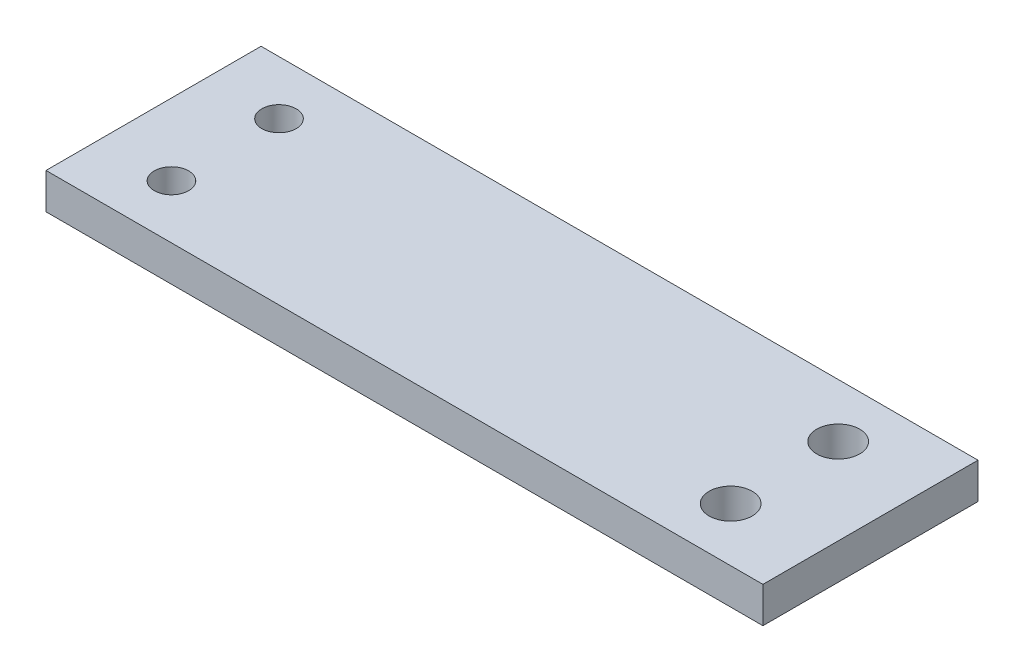
from build123d import *

# Parameters (mm, degrees)
SKIZZE3_W                            = 100
SKIZZE3_H                            = 5
AUFSATZ_LINEAR_AUSTRAGEN1_DEPTH      = 15
AUFSATZ_LINEAR_AUSTRAGEN1_DEPTH_BACK = 15
SKIZZE8_R                            = 3
SCHNITT_LINEAR_AUSTRAGEN1_DEPTH      = 21
SKIZZE10_R                           = 2.4
SCHNITT_LINEAR_AUSTRAGEN2_DEPTH      = 21


with BuildPart() as part:
    # Skizze3 → Aufsatz-Linear austragen1 (new body, two sides)
    with BuildSketch(Plane.XY) as aufsatz_linear_austragen1_sk:
        with Locations((15, 18.5)):
            Rectangle(SKIZZE3_W, SKIZZE3_H)
    extrude(amount=AUFSATZ_LINEAR_AUSTRAGEN1_DEPTH)
    extrude(aufsatz_linear_austragen1_sk.sketch, amount=-AUFSATZ_LINEAR_AUSTRAGEN1_DEPTH_BACK)

    # Skizze8 → Schnitt-Linear austragen1 (cut)
    with BuildSketch(Plane(origin=(0, 0, 0), x_dir=(1, 0, 0), z_dir=(0, 1, 0))):
        with Locations((53, 7.5)):
            Circle(SKIZZE8_R)
        with Locations((53, -7.5)):
            Circle(SKIZZE8_R)
    extrude(amount=SCHNITT_LINEAR_AUSTRAGEN1_DEPTH, mode=Mode.SUBTRACT)

    # Skizze10 → Schnitt-Linear austragen2 (cut)
    with BuildSketch(Plane(origin=(0, 0, 0), x_dir=(1, 0, 0), z_dir=(0, 1, 0))):
        with Locations((-25, 7.5)):
            Circle(SKIZZE10_R)
        with Locations((-25, -7.5)):
            Circle(SKIZZE10_R)
    extrude(amount=SCHNITT_LINEAR_AUSTRAGEN2_DEPTH, mode=Mode.SUBTRACT)


solid = part.part
